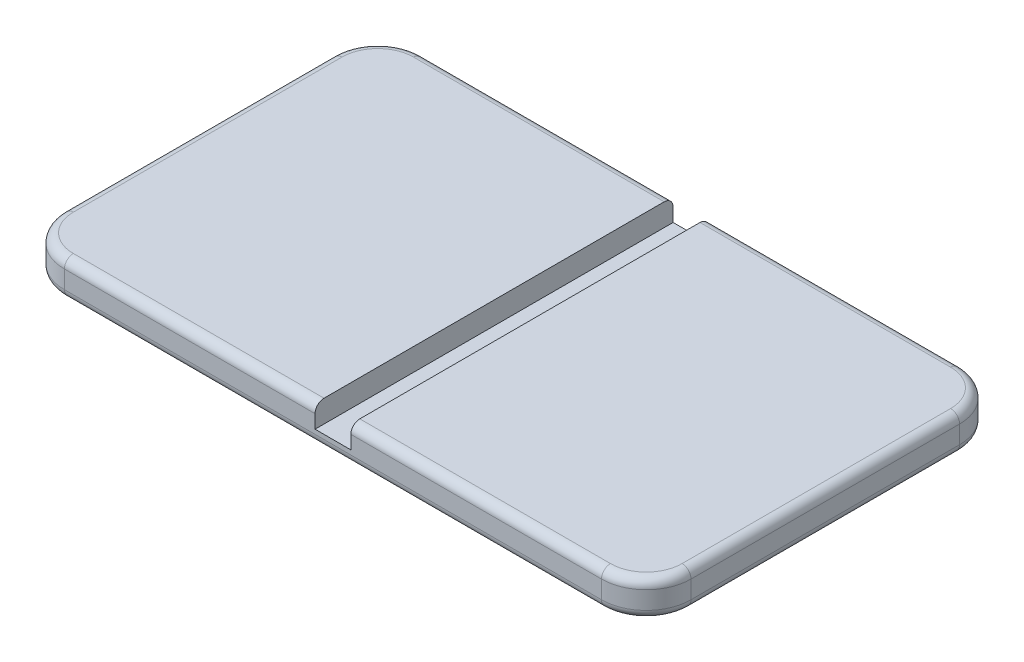
from build123d import *

# Parameters (mm, degrees)
SKICA1_W                 = 140
SKICA1_H                 = 80
P_IDAT_VYSUNUT_M1_DEPTH  = 8
ODEBRAT_VYSUNUT_M1_REACH = 82
SKICA2_W                 = 8
SKICA2_H                 = 5
ZAOBLIT1_R               = 10
ZAOBLIT3_R               = 2


with BuildPart() as part:
    # Skica1 → Přidat vysunutím1 (new body)
    with BuildSketch(Plane(origin=(0, 0, 0), x_dir=(1, 0, 0), z_dir=(0, 1, 0))):
        with Locations((70, 40)):
            Rectangle(SKICA1_W, SKICA1_H)
    extrude(amount=P_IDAT_VYSUNUT_M1_DEPTH)

    # Skica2 → Odebrat vysunutím1 (cut, up to next)
    with BuildSketch(Plane.XY, mode=Mode.PRIVATE) as odebrat_vysunut_m1_sk1:
        with Locations((70, 5.5)):
            Rectangle(SKICA2_W, SKICA2_H)
    odebrat_vysunut_m1_tool1 = extrude(odebrat_vysunut_m1_sk1.sketch, amount=-ODEBRAT_VYSUNUT_M1_REACH, mode=Mode.PRIVATE) & part.part
    add(odebrat_vysunut_m1_tool1.solids().sort_by_distance((70, 5.5, 0))[0], mode=Mode.SUBTRACT)

    # Zaoblit1
    zaoblit1_edges = [part.edges().sort_by_distance(p)[0] for p in [
        (0, 4, -80),
        (140, 4, -80),
        (140, 4, 0),
        (0, 4, 0),
    ]]
    fillet(zaoblit1_edges, radius=ZAOBLIT1_R)

    # Zaoblit3
    zaoblit3_edges = [part.edges().sort_by_distance(p)[0] for p in [
        (102, 8, 0),
        (38, 8, -80),
        (0, 0, -40),
        (0, 8, -40),
        (70, 0, -80),
        (140, 0, -40),
        (70, 0, 0),
        (2.928932188, 0, -2.928932188),
        (137.071067812, 0, -2.928932188),
        (137.071067812, 0, -77.071067812),
        (2.928932188, 0, -77.071067812),
        (102, 8, -80),
        (38, 8, 0),
        (2.928932188, 8, -2.928932188),
        (2.928932188, 8, -77.071067812),
        (140, 8, -40),
        (137.071067812, 8, -2.928932188),
        (137.071067812, 8, -77.071067812),
    ]]
    fillet(zaoblit3_edges, radius=ZAOBLIT3_R)


solid = part.part
